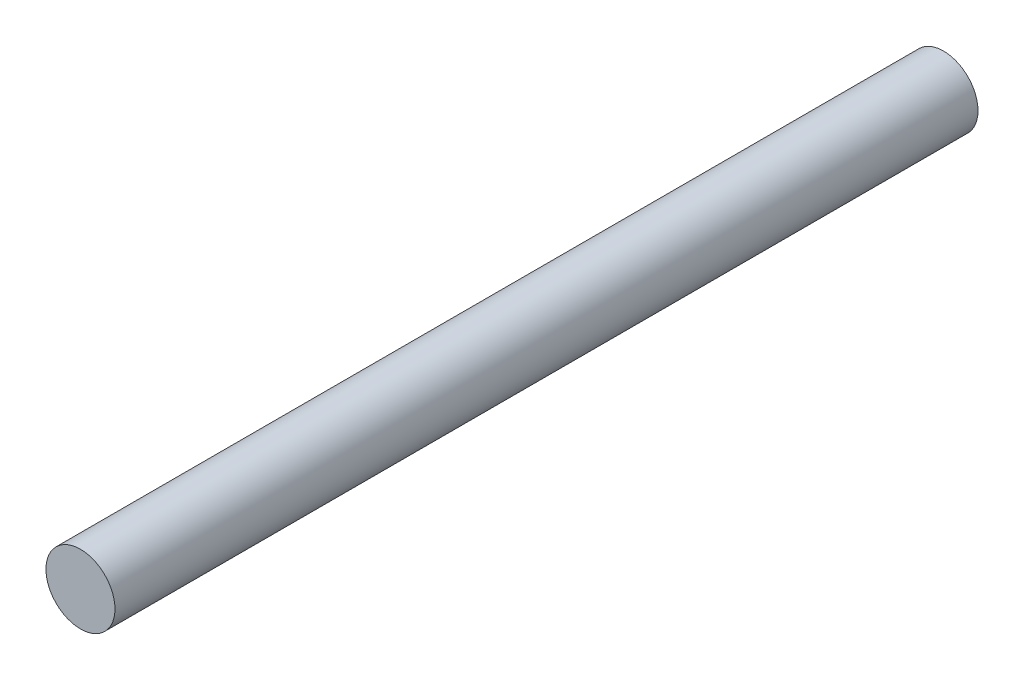
from build123d import *

# Parameters (mm, degrees)
SKETCH3_R           = 2.54
BOSS_EXTRUDE2_DEPTH = 63.5


with BuildPart() as part:
    # Sketch3 → Boss-Extrude2 (new body)
    with BuildSketch(Plane.XY):
        Circle(SKETCH3_R)
    extrude(amount=BOSS_EXTRUDE2_DEPTH)


solid = part.part
